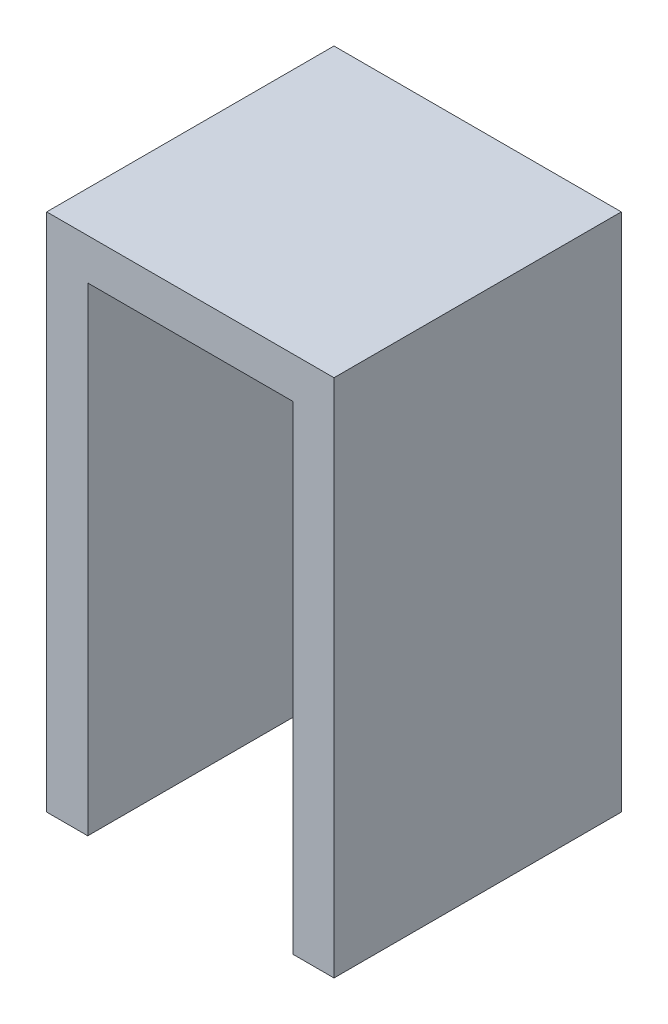
from build123d import *

# Parameters (mm, degrees)
SKETCH_1_W          = 21
SKETCH_1_H          = 38
SKETCH_1_W_2        = 15
SKETCH_1_H_2        = 32
EXTRUDE_1_DEPTH     = 18
SKETCH_2_W          = 21
SKETCH_2_H          = 38
EXTRUDE_2_DEPTH     = 3
SKETCH_3_W          = 15
SKETCH_3_H          = 15
CUT_EXTRUDE_1_DEPTH = 3


with BuildPart() as part:
    # 草圖1 → 填料-伸長1 (new body)
    with BuildSketch(Plane.XY):
        with Locations((-0.498060931, -7.683431953)):
            Rectangle(SKETCH_1_W, SKETCH_1_H)
        with Locations((-0.498060931, -7.683431953)):
            Rectangle(SKETCH_1_W_2, SKETCH_1_H_2, mode=Mode.SUBTRACT)
    extrude(amount=EXTRUDE_1_DEPTH)

    # 草圖2 → 填料-伸長2 (add)
    with BuildSketch(Plane(origin=(0, 0, 0), x_dir=(-1, 0, 0), z_dir=(0, 0, -1))):
        with Locations((0.498060931, -7.683431953)):
            Rectangle(SKETCH_2_W, SKETCH_2_H)
    extrude(amount=EXTRUDE_2_DEPTH)

    # 草圖3 → 除料-伸長1 (cut)
    with BuildSketch(Plane.XZ.offset(26.683431953)):
        with Locations((-0.498060931, 10.5)):
            Rectangle(SKETCH_3_W, SKETCH_3_H)
    extrude(amount=-CUT_EXTRUDE_1_DEPTH, mode=Mode.SUBTRACT)


solid = part.part
